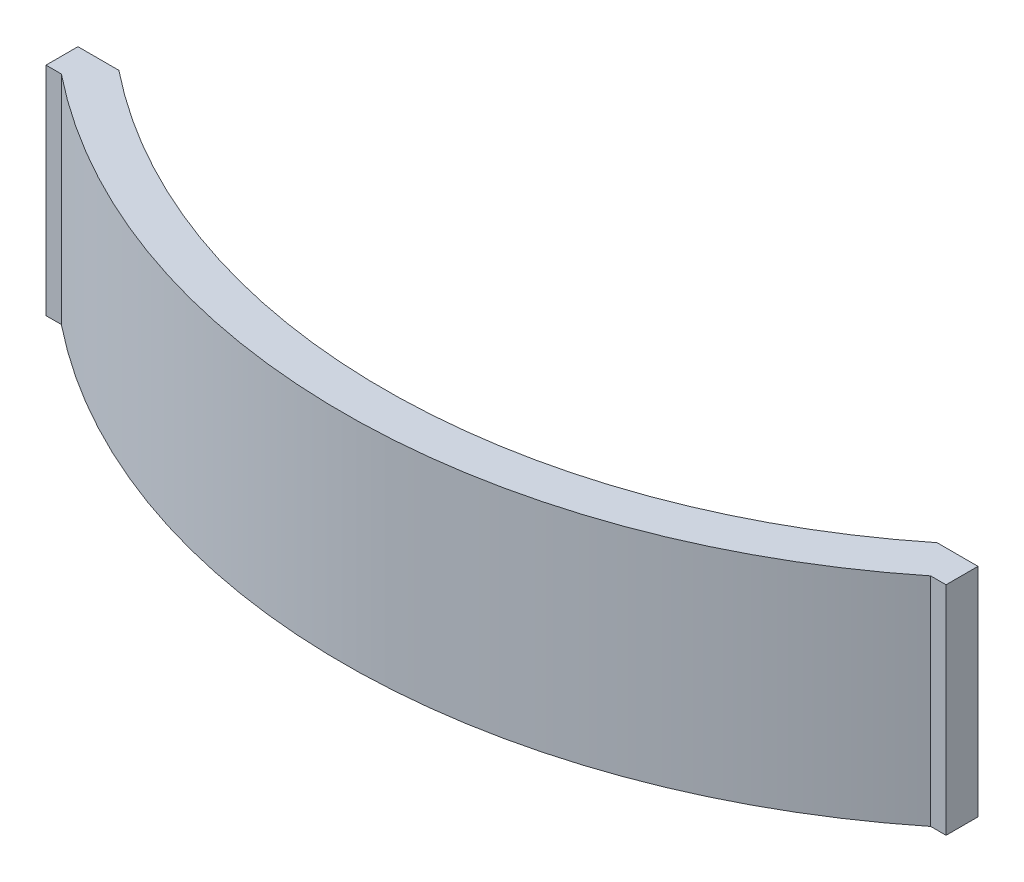
from build123d import *

# Parameters (mm, degrees)
BOSS_EXTRUDE1_DEPTH = 16.8402


with BuildPart() as part:
    # Sketch2 → Boss-Extrude1 (new body)
    with BuildSketch(Plane(origin=(0, 0, 0), x_dir=(1, 0, 0), z_dir=(0, 1, 0))):
        with BuildLine():
            Line((-34.925635, -39.65573729), (-31.75, -39.65573729))
            ThreePointArc((-31.75, -39.65573729), (0, -50.8), (31.75, -39.65573729))
            Line((31.75, -39.65573729), (34.925635, -39.655737384))
            Line((34.925635, -39.655737384), (34.925635, -42.13422087))
            Line((34.925635, -42.13422087), (33.734375, -42.13422087))
            ThreePointArc((33.734375, -42.13422087), (0, -53.975), (-33.734375, -42.13422087))
            Line((-33.734375, -42.13422087), (-34.925635, -42.13422087))
            Line((-34.925635, -42.13422087), (-34.925635, -39.65573729))
        make_face()
    extrude(amount=BOSS_EXTRUDE1_DEPTH)


solid = part.part
